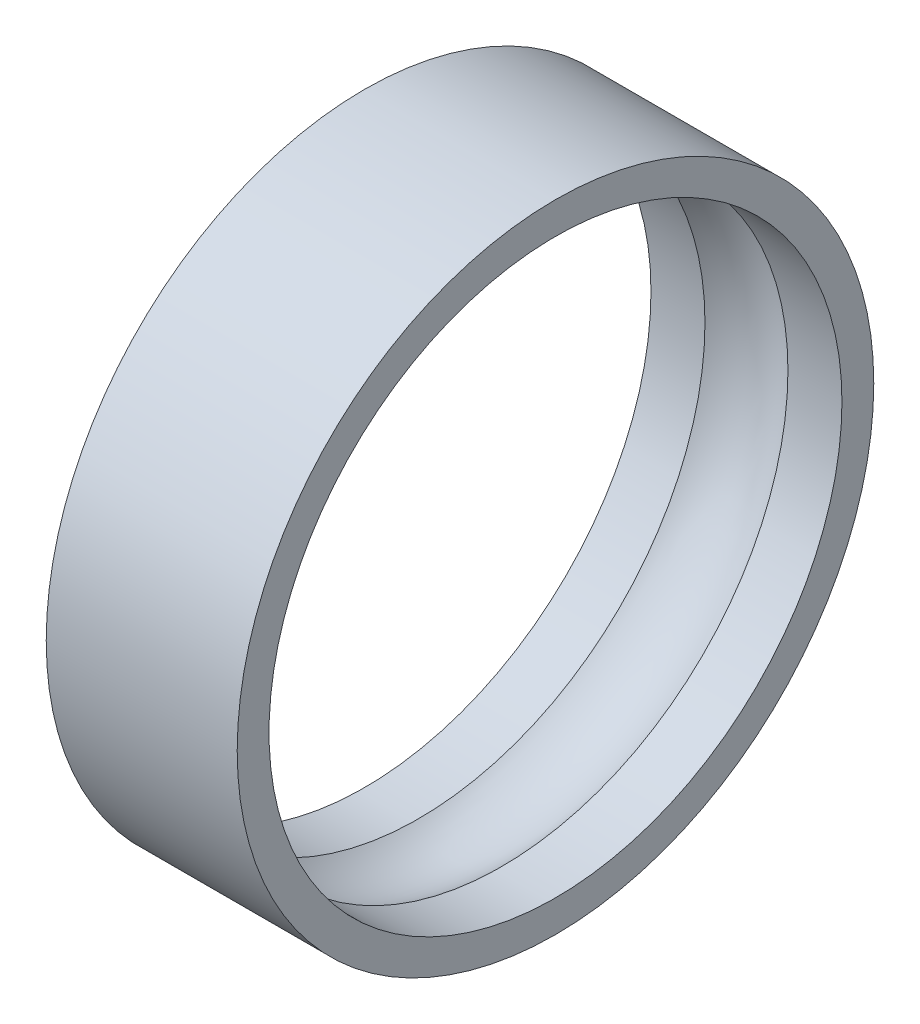
from build123d import *


with BuildPart() as part:
    # 草图1 → 旋转1 (revolve)
    with BuildSketch(Plane.XY):
        with BuildLine():
            Line((-6, 5.75), (6, 5.75))
            Line((6, 5.75), (6, 3.75))
            Line((6, 3.75), (2.606962772, 3.75))
            ThreePointArc((2.606962772, 3.75), (0, 4.582065281), (-2.606962772, 3.75))
            Line((-2.606962772, 3.75), (-6, 3.75))
            Line((-6, 3.75), (-6, 5.75))
        make_face()
    revolve(axis=Axis((21.715121114, -14.25, 0), (-1, 0, 0)))


solid = part.part
